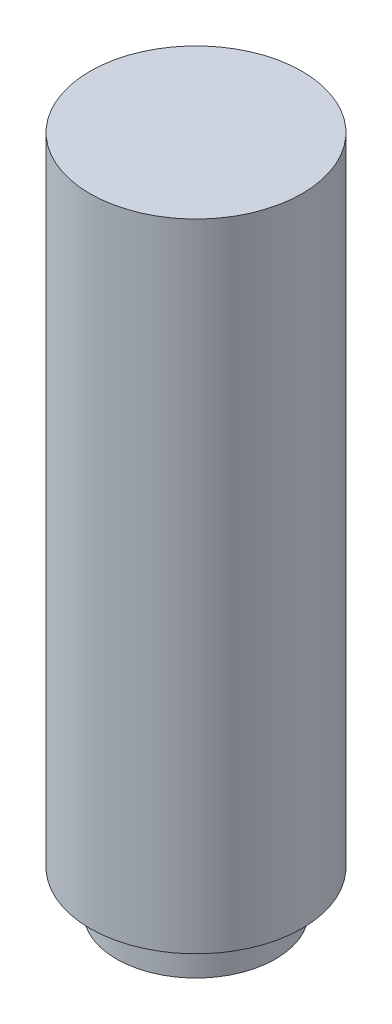
from build123d import *

# Parameters (mm, degrees)
SKETCH1_R           = 40
BOSS_EXTRUDE1_DEPTH = 240
SKETCH2_R           = 30
BOSS_EXTRUDE2_DEPTH = 15
SKETCH3_R           = 12.5
CUT_EXTRUDE2_DEPTH  = 10


with BuildPart() as part:
    # Sketch1 → Boss-Extrude1 (new body)
    with BuildSketch(Plane(origin=(0, 0, 0), x_dir=(1, 0, 0), z_dir=(0, 1, 0))):
        Circle(SKETCH1_R)
    extrude(amount=BOSS_EXTRUDE1_DEPTH)

    # Sketch2 → Boss-Extrude2 (add)
    with BuildSketch(Plane.XZ):
        Circle(SKETCH2_R)
    extrude(amount=BOSS_EXTRUDE2_DEPTH)

    # Sketch3 → Cut-Extrude2 (cut)
    with BuildSketch(Plane.XZ.offset(15)):
        Circle(SKETCH3_R)
    extrude(amount=-CUT_EXTRUDE2_DEPTH, mode=Mode.SUBTRACT)


solid = part.part
